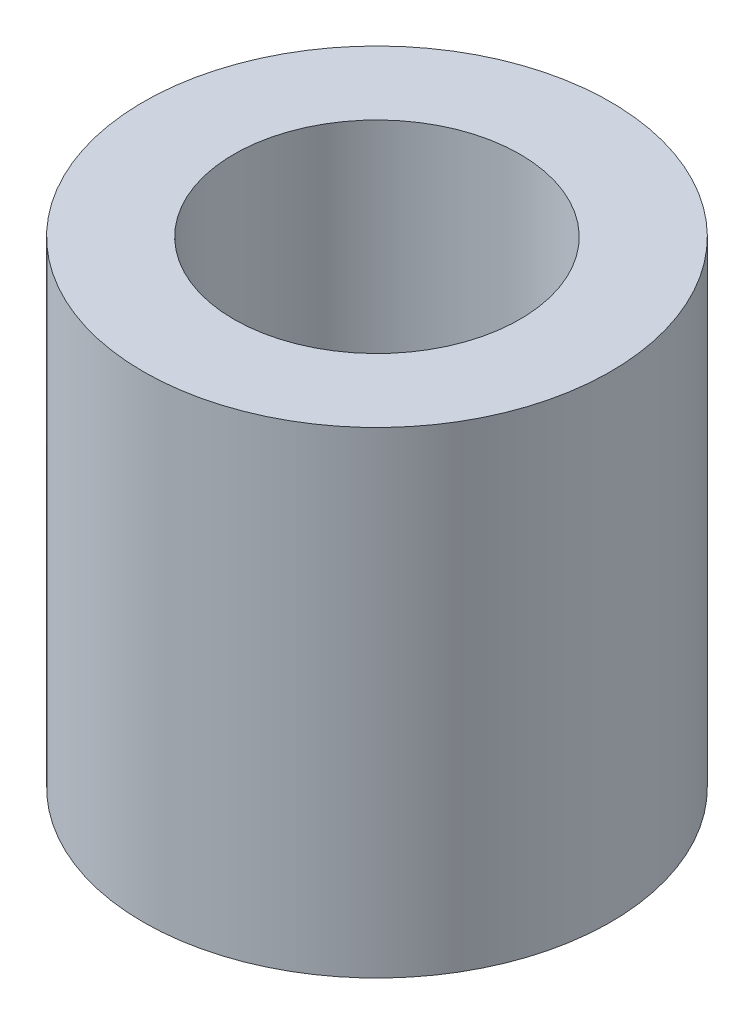
from build123d import *

# Parameters (mm, degrees)
SKETCH1_R           = 4.9
BOSS_EXTRUDE1_DEPTH = 10
SKETCH6_R           = 3
CUT_EXTRUDE3_DEPTH  = 11


with BuildPart() as part:
    # Sketch1 → Boss-Extrude1 (new body)
    with BuildSketch(Plane(origin=(0, 0, 0), x_dir=(1, 0, 0), z_dir=(0, 1, 0))):
        Circle(SKETCH1_R)
    extrude(amount=BOSS_EXTRUDE1_DEPTH)

    # Sketch6 → Cut-Extrude3 (cut, through all)
    with BuildSketch(Plane(origin=(0, 10, 0), x_dir=(1, 0, 0), z_dir=(0, 1, 0))):
        Circle(SKETCH6_R)
    extrude(amount=-CUT_EXTRUDE3_DEPTH, mode=Mode.SUBTRACT)


solid = part.part
